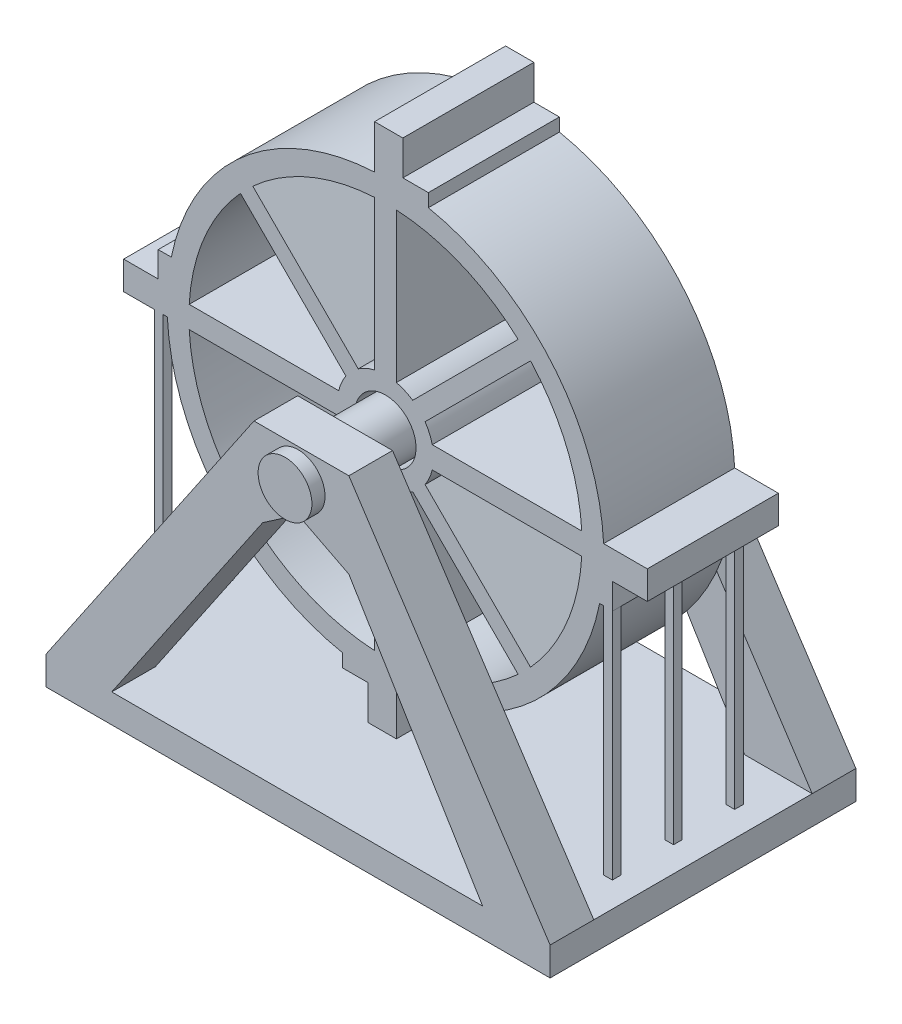
from build123d import *

# Parameters (mm, degrees)
CROQUIS1_W                   = 115.375917884
CROQUIS1_H                   = 6.540670241
SALIENTE_EXTRUIR1_DEPTH      = 70
CROQUIS4_W                   = 57.687958942
CROQUIS4_H                   = 10
SALIENTE_EXTRUIR2_DEPTH      = 70
CORTAR_EXTRUIR2_DEPTH        = 35
CORTAR_EXTRUIR3_DEPTH        = 35
CROQUIS7_R                   = 6.05660598
CORTAR_EXTRUIR4_DEPTH        = 35
CROQUIS10_R                  = 6.159768466
SALIENTE_EXTRUIR3_DEPTH      = 73
SALIENTE_EXTRUIR3_DEPTH_BACK = 4
CROQUIS25_R                  = 7
SALIENTE_EXTRUIR12_DEPTH     = 15
CROQUIS29_W                  = 12
CROQUIS29_H                  = 53.389522775
CORTAR_EXTRUIR6_DEPTH        = 3
CROQUIS33_W                  = 12
CROQUIS33_H                  = 60.702688994
CORTAR_EXTRUIR8_DEPTH        = 3


with BuildPart() as part:
    # Croquis1 → Saliente-Extruir1 (new body)
    with BuildSketch(Plane.XY):
        with Locations((57.687958942, 3.270335121)):
            Rectangle(CROQUIS1_W, CROQUIS1_H)
    extrude(amount=SALIENTE_EXTRUIR1_DEPTH)

    # Croquis4 → Saliente-Extruir2 (add)
    with BuildSketch(Plane(origin=(0, 6.540670241, 0), x_dir=(1, 0, 0), z_dir=(0, 1, 0))):
        with Locations((28.843979471, -5)):
            Rectangle(CROQUIS4_W, CROQUIS4_H)
        with Locations((86.531938413, -5)):
            Rectangle(CROQUIS4_W, CROQUIS4_H)
        with Locations((28.843979471, -65)):
            Rectangle(CROQUIS4_W, CROQUIS4_H)
        with Locations((86.531938413, -65)):
            Rectangle(CROQUIS4_W, CROQUIS4_H)
    extrude(amount=SALIENTE_EXTRUIR2_DEPTH)

    # Croquis5 → Cortar-Extruir2 (cut, symmetric)
    with BuildSketch(Plane.XY.offset(10)):
        Polygon((0, 6.540670241), (47.590279049, 76.540670241), (0, 76.540670241), align=None)
        Polygon((57.687958942, 6.540670241), (57.687958942, 62.946048228), (49.583363908, 57.38419593), (15.016827117, 6.540670241), align=None)
    extrude(amount=CORTAR_EXTRUIR2_DEPTH, both=True, mode=Mode.SUBTRACT)

    # Croquis6 → Cortar-Extruir3 (cut, symmetric)
    with BuildSketch(Plane.XY.offset(10)):
        Polygon((69.303593334, 57.028333792), (57.687958942, 62.946048228), (57.687958942, 6.540670241), (99.924183433, 6.540670241), align=None)
        Polygon((69.303593334, 76.540670241), (115.375917884, 6.540670241), (115.375917884, 76.540670241), align=None)
        with BuildLine():
            ThreePointArc((57.687958942, 75.799965215), (51.631352961, 69.743359235), (57.687958942, 63.686753254))
            Line((57.687958942, 63.686753254), (57.687958942, 75.799965215))
        make_face()
        with BuildLine():
            Line((57.687958942, 75.799965215), (57.687958942, 63.686753254))
            ThreePointArc((57.687958942, 63.686753254), (61.970626102, 65.460692075), (63.744564922, 69.743359235))
            ThreePointArc((63.744564922, 69.743359235), (61.970626102, 74.026026395), (57.687958942, 75.799965215))
        make_face()
    extrude(amount=CORTAR_EXTRUIR3_DEPTH, both=True, mode=Mode.SUBTRACT)

    # Croquis7 → Cortar-Extruir4 (cut, symmetric)
    with BuildSketch(Plane(origin=(0, 0, 60), x_dir=(-1, 0, 0), z_dir=(0, 0, -1))):
        Polygon((0, 76.540670241), (-47.590279049, 76.540670241), (0, 6.540670241), align=None)
        Polygon((-69.303593334, 57.028333792), (-99.924183433, 6.540670241), (-15.016827117, 6.540670241), (-49.583363908, 57.38419593), (-57.687958942, 62.946048228), align=None)
        Polygon((-115.375917884, 76.540670241), (-115.375917884, 6.540670241), (-69.303593334, 76.540670241), align=None)
        with Locations((-57.687958942, 69.743359235)):
            Circle(CROQUIS7_R)
    extrude(amount=CORTAR_EXTRUIR4_DEPTH, both=True, mode=Mode.SUBTRACT)

    # Croquis10 → Saliente-Extruir3 (add, two sides)
    with BuildSketch(Plane.XY) as saliente_extruir3_sk:
        with Locations((57.687958942, 69.743359235)):
            Circle(CROQUIS10_R)
    extrude(amount=SALIENTE_EXTRUIR3_DEPTH)
    extrude(saliente_extruir3_sk.sketch, amount=-SALIENTE_EXTRUIR3_DEPTH_BACK)


with BuildPart() as body_2:
    # Croquis25 → Saliente-Extruir12 (new body, symmetric)
    with BuildSketch(Plane(origin=(0, 0, 35), x_dir=(-1, 0, 0), z_dir=(0, 0, -1))):
        with BuildLine():
            Line((-7.750498053, 67.243359235), (-6.761041311, 67.243359235))
            Line((-6.761041311, 67.243359235), (-6.761041311, 6.540670241))
            Line((-6.761041311, 6.540670241), (-4.761041311, 6.540670241))
            Line((-4.761041311, 6.540670241), (-4.761041311, 67.243359235))
            Line((-4.761041311, 67.243359235), (2.249501947, 67.243359235))
            Line((2.249501947, 67.243359235), (2.249501947, 73.716885116))
            Line((2.249501947, 73.716885116), (-5.660397624, 73.716885116))
            Line((-5.660397624, 73.716885116), (-5.660397624, 79.556525453))
            Line((-5.660397624, 79.556525453), (-8.660397624, 79.556525453))
            ThreePointArc((-8.660397624, 79.556525453), (-25.034289171, 107.608090192), (-55.187958942, 119.680820123))
            Line((-55.187958942, 119.680820123), (-55.187958942, 129.680820123))
            Line((-55.187958942, 129.680820123), (-61.661484823, 129.680820123))
            Line((-61.661484823, 129.680820123), (-61.661484823, 121.770920553))
            Line((-61.661484823, 121.770920553), (-67.50112516, 121.770920553))
            Line((-67.50112516, 121.770920553), (-67.50112516, 118.770920553))
            ThreePointArc((-67.50112516, 118.770920553), (-95.552689899, 102.397029006), (-107.62541983, 72.243359235))
            Line((-107.62541983, 72.243359235), (-117.62541983, 72.243359235))
            Line((-117.62541983, 72.243359235), (-117.62541983, 65.769833354))
            Line((-117.62541983, 65.769833354), (-109.71552026, 65.769833354))
            Line((-109.71552026, 65.769833354), (-109.71552026, 59.930193016))
            Line((-109.71552026, 59.930193016), (-109.62541983, 59.930193016))
            Line((-109.62541983, 59.930193016), (-109.62541983, 6.540670241))
            Line((-109.62541983, 6.540670241), (-107.62541983, 6.540670241))
            Line((-107.62541983, 6.540670241), (-107.62541983, 59.930193016))
            Line((-107.62541983, 59.930193016), (-106.71552026, 59.930193016))
            ThreePointArc((-106.71552026, 59.930193016), (-90.341628713, 31.878628277), (-60.187958942, 19.805898346))
            Line((-60.187958942, 19.805898346), (-60.187958942, 9.805898346))
            Line((-60.187958942, 9.805898346), (-53.714433061, 9.805898346))
            Line((-53.714433061, 9.805898346), (-53.714433061, 17.715797917))
            Line((-53.714433061, 17.715797917), (-47.874792723, 17.715797917))
            Line((-47.874792723, 17.715797917), (-47.874792723, 20.715797917))
            ThreePointArc((-47.874792723, 20.715797917), (-19.823227985, 37.089689464), (-7.750498053, 67.243359235))
        make_face()
        with BuildLine():
            Line((-60.187958942, 59.031216592), (-60.187958942, 24.812857346))
            ThreePointArc((-60.187958942, 24.812857346), (-75.139706125, 28.265214143), (-88.06210803, 36.540783022))
            Line((-88.06210803, 36.540783022), (-63.92227465, 60.680616402))
            ThreePointArc((-63.92227465, 60.680616402), (-62.132303399, 59.681162539), (-60.187958942, 59.031216592))
        make_face(mode=Mode.SUBTRACT)
        with BuildLine():
            Line((-66.750701775, 63.509043527), (-90.890535155, 39.369210147))
            ThreePointArc((-90.890535155, 39.369210147), (-99.166104034, 52.291612052), (-102.618460831, 67.243359235))
            Line((-102.618460831, 67.243359235), (-68.400101585, 67.243359235))
            ThreePointArc((-68.400101585, 67.243359235), (-67.750155638, 65.299014777), (-66.750701775, 63.509043527))
        make_face(mode=Mode.SUBTRACT)
        with BuildLine():
            Line((-51.453643234, 60.680616402), (-27.313809854, 36.540783022))
            ThreePointArc((-27.313809854, 36.540783022), (-40.236211759, 28.265214143), (-55.187958942, 24.812857346))
            Line((-55.187958942, 24.812857346), (-55.187958942, 59.031216592))
            ThreePointArc((-55.187958942, 59.031216592), (-53.243614485, 59.681162539), (-51.453643234, 60.680616402))
        make_face(mode=Mode.SUBTRACT)
        with Locations((-57.687958942, 69.743359235)):
            Circle(CROQUIS25_R, mode=Mode.SUBTRACT)
        with BuildLine():
            Line((-46.975816299, 67.243359235), (-12.757457053, 67.243359235))
            ThreePointArc((-12.757457053, 67.243359235), (-16.20981385, 52.291612052), (-24.485382729, 39.369210147))
            Line((-24.485382729, 39.369210147), (-48.625216109, 63.509043527))
            ThreePointArc((-48.625216109, 63.509043527), (-47.625762246, 65.299014777), (-46.975816299, 67.243359235))
        make_face(mode=Mode.SUBTRACT)
        with BuildLine():
            Line((-90.890535155, 100.117508323), (-66.750701775, 75.977674943))
            ThreePointArc((-66.750701775, 75.977674943), (-67.750155638, 74.187703692), (-68.400101585, 72.243359235))
            Line((-68.400101585, 72.243359235), (-102.618460831, 72.243359235))
            ThreePointArc((-102.618460831, 72.243359235), (-99.166104034, 87.195106418), (-90.890535155, 100.117508323))
        make_face(mode=Mode.SUBTRACT)
        with BuildLine():
            Line((-63.92227465, 78.806102068), (-88.06210803, 102.945935448))
            ThreePointArc((-88.06210803, 102.945935448), (-75.139706125, 111.221504327), (-60.187958942, 114.673861124))
            Line((-60.187958942, 114.673861124), (-60.187958942, 80.455501878))
            ThreePointArc((-60.187958942, 80.455501878), (-62.132303399, 79.805555931), (-63.92227465, 78.806102068))
        make_face(mode=Mode.SUBTRACT)
        with BuildLine():
            Line((-27.313809854, 102.945935448), (-51.453643234, 78.806102068))
            ThreePointArc((-51.453643234, 78.806102068), (-53.243614485, 79.805555931), (-55.187958942, 80.455501878))
            Line((-55.187958942, 80.455501878), (-55.187958942, 114.673861124))
            ThreePointArc((-55.187958942, 114.673861124), (-40.236211759, 111.221504327), (-27.313809854, 102.945935448))
        make_face(mode=Mode.SUBTRACT)
        with BuildLine():
            Line((-48.625216109, 75.977674943), (-24.485382729, 100.117508323))
            ThreePointArc((-24.485382729, 100.117508323), (-16.20981385, 87.195106418), (-12.757457053, 72.243359235))
            Line((-12.757457053, 72.243359235), (-46.975816299, 72.243359235))
            ThreePointArc((-46.975816299, 72.243359235), (-47.625762246, 74.187703692), (-48.625216109, 75.977674943))
        make_face(mode=Mode.SUBTRACT)
    extrude(amount=SALIENTE_EXTRUIR12_DEPTH, both=True)

    # Croquis29 → Cortar-Extruir6 (cut)
    with BuildSketch(Plane(origin=(109.62541983, 0, 0), x_dir=(0, 0, -1), z_dir=(1, 0, 0))):
        with Locations((-42, 33.235431629)):
            Rectangle(CROQUIS29_W, CROQUIS29_H)
        with Locations((-28, 33.235431629)):
            Rectangle(CROQUIS29_W, CROQUIS29_H)
    extrude(amount=-CORTAR_EXTRUIR6_DEPTH, mode=Mode.SUBTRACT)

    # Croquis33 → Cortar-Extruir8 (cut)
    with BuildSketch(Plane.ZY.offset(-4.761041311)):
        with Locations((28, 36.892014738)):
            Rectangle(CROQUIS33_W, CROQUIS33_H)
        with Locations((42, 36.892014738)):
            Rectangle(CROQUIS33_W, CROQUIS33_H)
    extrude(amount=-CORTAR_EXTRUIR8_DEPTH, mode=Mode.SUBTRACT)


solid = Compound([part.part, body_2.part])
